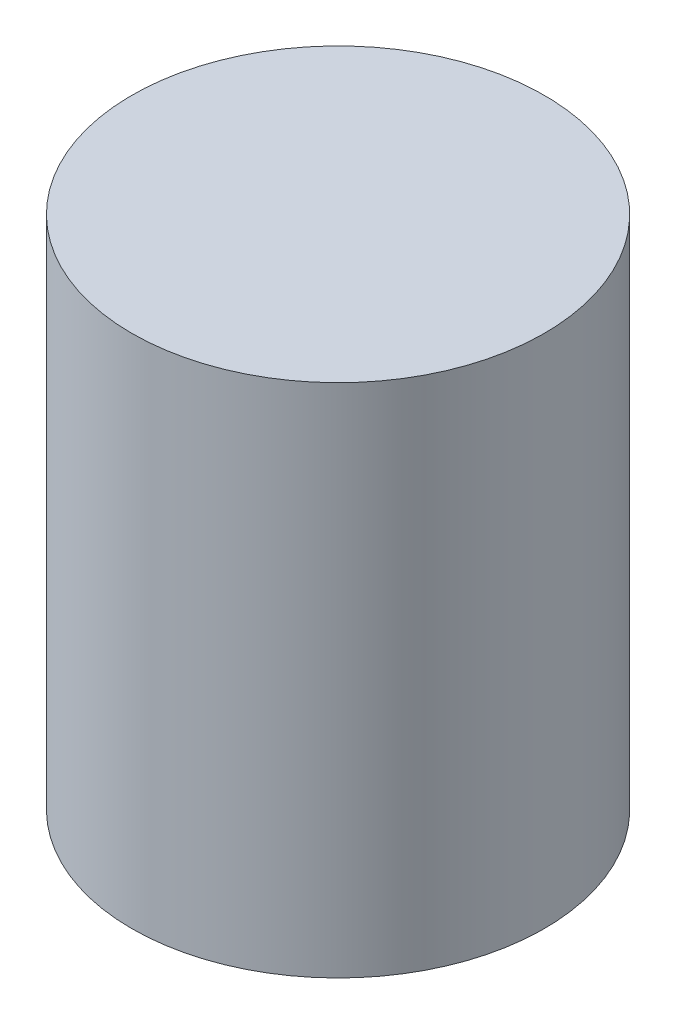
from build123d import *

# Parameters (mm, degrees)
SKETCH1_R           = 4
BOSS_EXTRUDE1_DEPTH = 10


with BuildPart() as part:
    # Sketch1 → Boss-Extrude1 (new body)
    with BuildSketch(Plane(origin=(0, 0, 0), x_dir=(1, 0, 0), z_dir=(0, 1, 0))):
        Circle(SKETCH1_R)
    extrude(amount=BOSS_EXTRUDE1_DEPTH)


solid = part.part
